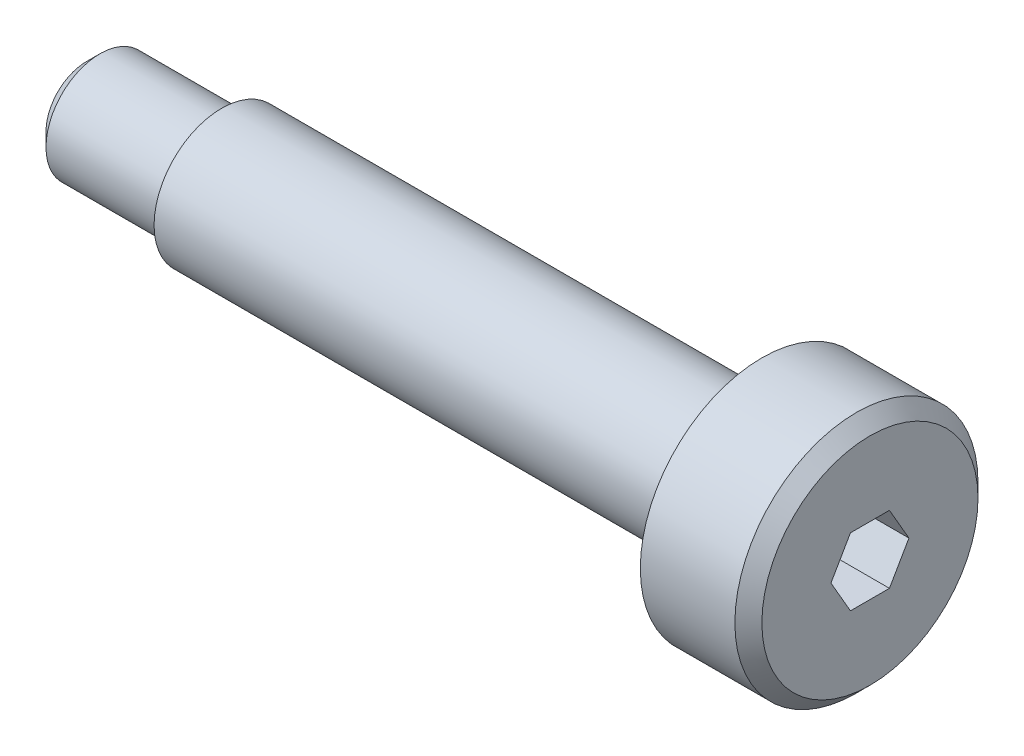
from build123d import *

# Parameters (mm, degrees)
CUT_EXTRUDE1_DEPTH = 4


with BuildPart() as part:
    # Sketch1 → Revolve1 (revolve)
    with BuildSketch(Plane.XY):
        Polygon((0, 0), (29, 0), (29, 4), (28.5, 4.5), (25, 4.5), (25, 2.5), (5, 2.5), (5, 2), (0.5, 2), (0, 1.5), align=None)
    revolve(axis=Axis((0, 0, 0), (1, 0, 0)))

    # Sketch2 → Cut-Extrude1 (cut)
    with BuildSketch(Plane(origin=(29, 0, 0), x_dir=(0, 0, -1), z_dir=(1, 0, 0))):
        Polygon((1.443375673, 0), (0.721687836, 1.25), (-0.721687836, 1.25), (-1.443375673, 0), (-0.721687836, -1.25), (0.721687836, -1.25), align=None)
    extrude(amount=-CUT_EXTRUDE1_DEPTH, mode=Mode.SUBTRACT)


solid = part.part
